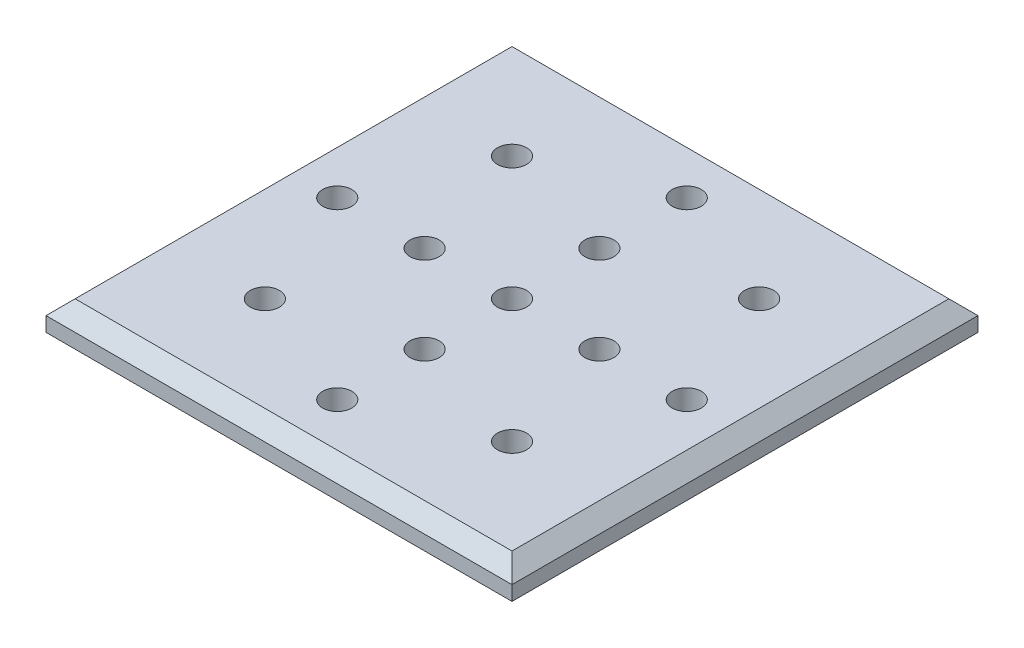
from build123d import *

# Parameters (mm, degrees)
SKETCH1_W           = 101.6
SKETCH1_H           = 101.6
BOSS_EXTRUDE1_DEPTH = 9.525
SKETCH2_W           = 101.6
SKETCH2_H           = 101.6
SKETCH2_W_2         = 94.996
SKETCH2_H_2         = 94.996
CUT_EXTRUDE1_DEPTH  = 3.175
CHAMFER1_SIZE       = 3.175
SKETCH9_R           = 3.175
CUT_EXTRUDE3_DEPTH  = 55.118


with BuildPart() as part:
    # Sketch1 → Boss-Extrude1 (new body)
    with BuildSketch(Plane(origin=(0, 0, 0), x_dir=(1, 0, 0), z_dir=(0, 1, 0))):
        Rectangle(SKETCH1_W, SKETCH1_H)
    extrude(amount=BOSS_EXTRUDE1_DEPTH)

    # Sketch2 → Cut-Extrude1 (cut)
    with BuildSketch(Plane.XZ):
        Rectangle(SKETCH2_W, SKETCH2_H)
        Rectangle(SKETCH2_W_2, SKETCH2_H_2, mode=Mode.SUBTRACT)
    extrude(amount=-CUT_EXTRUDE1_DEPTH, mode=Mode.SUBTRACT)

    # Chamfer1
    chamfer1_edges = [part.edges().sort_by_distance(p)[0] for p in [
        (-50.8, 9.525, 0),
        (0, 9.525, 50.8),
        (50.8, 9.525, 0),
        (0, 9.525, -50.8),
    ]]
    chamfer(chamfer1_edges, length=CHAMFER1_SIZE)

    # Sketch9 → Cut-Extrude3 (cut)
    with BuildSketch(Plane(origin=(0, 0, 0), x_dir=(1, 0, 0), z_dir=(0, 1, 0))):
        Circle(SKETCH9_R)
        with Locations((19.05, 0)):
            Circle(SKETCH9_R)
        with Locations((0, -19.05)):
            Circle(SKETCH9_R)
        with Locations((-19.05, 0)):
            Circle(SKETCH9_R)
        with Locations((0, 19.05)):
            Circle(SKETCH9_R)
        with Locations((38.1, 0)):
            Circle(SKETCH9_R)
        with Locations((26.940768363, -26.940768363)):
            Circle(SKETCH9_R)
        with Locations((0, -38.1)):
            Circle(SKETCH9_R)
        with Locations((-26.940768363, -26.940768363)):
            Circle(SKETCH9_R)
        with Locations((-38.1, 0)):
            Circle(SKETCH9_R)
        with Locations((-26.940768363, 26.940768363)):
            Circle(SKETCH9_R)
        with Locations((0, 38.1)):
            Circle(SKETCH9_R)
        with Locations((26.940768363, 26.940768363)):
            Circle(SKETCH9_R)
    extrude(amount=CUT_EXTRUDE3_DEPTH, mode=Mode.SUBTRACT)


solid = part.part
